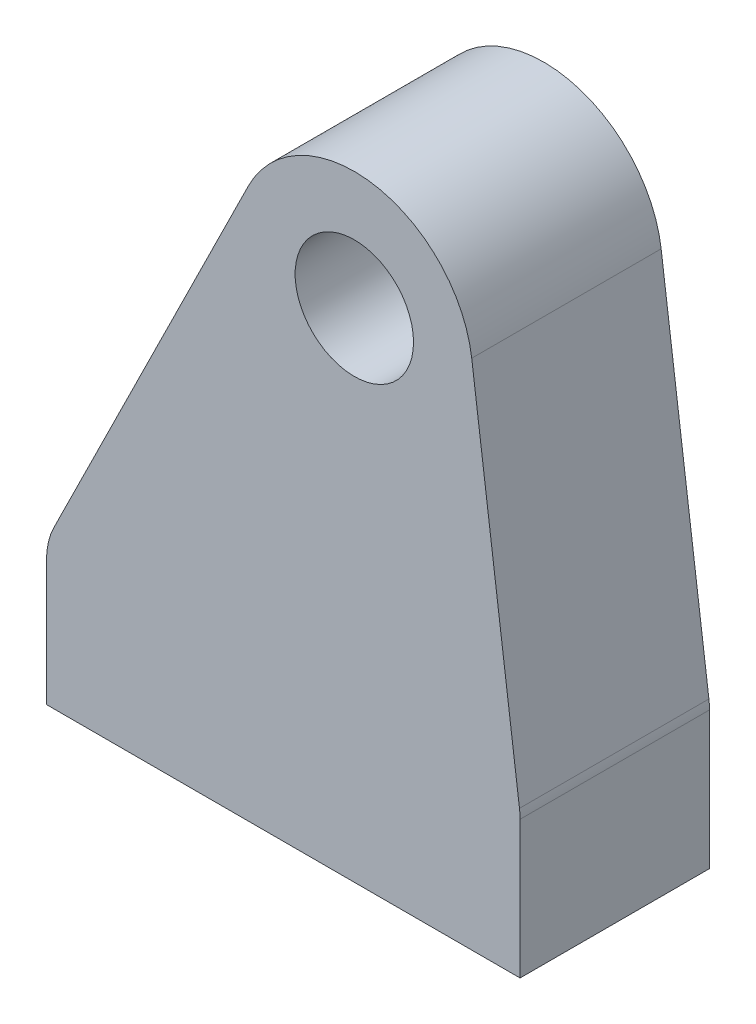
from build123d import *

# Parameters (mm, degrees)
SKETCH_1_R          = 2.5
EXTRUDE_1_DEPTH     = 8
SKETCH_2_R          = 1.5
CUT_EXTRUDE_1_DEPTH = 10
FILLET_1_R          = 3


with BuildPart() as part:
    # 草图1 → 凸台-拉伸1 (new body)
    with BuildSketch(Plane.XY):
        with BuildLine():
            Line((-10, 0), (10, 0))
            Line((10, 0), (10, 6))
            Line((10, 6), (7.957956343, 21.647046293))
            ThreePointArc((7.957956343, 21.647046293), (3.820468041, 25.932223859), (-1.481479577, 23.2172823))
            Line((-1.481479577, 23.2172823), (-10, 6))
            Line((-10, 6), (-10, 0))
        make_face()
        with Locations((3, 21)):
            Circle(SKETCH_1_R, mode=Mode.SUBTRACT)
    extrude(amount=EXTRUDE_1_DEPTH)

    # 草图2 → 切除-拉伸1 (cut)
    with BuildSketch(Plane.XZ):
        with Locations((-6, 4)):
            Circle(SKETCH_2_R)
        with Locations((6, 4)):
            Circle(SKETCH_2_R)
    extrude(amount=-CUT_EXTRUDE_1_DEPTH, mode=Mode.SUBTRACT)

    # 圆角1
    fillet_1_edges = [part.edges().sort_by_distance(p)[0] for p in [
        (-10, 6, 4),
        (10, 6, 4),
    ]]
    fillet(fillet_1_edges, radius=FILLET_1_R)


solid = part.part
